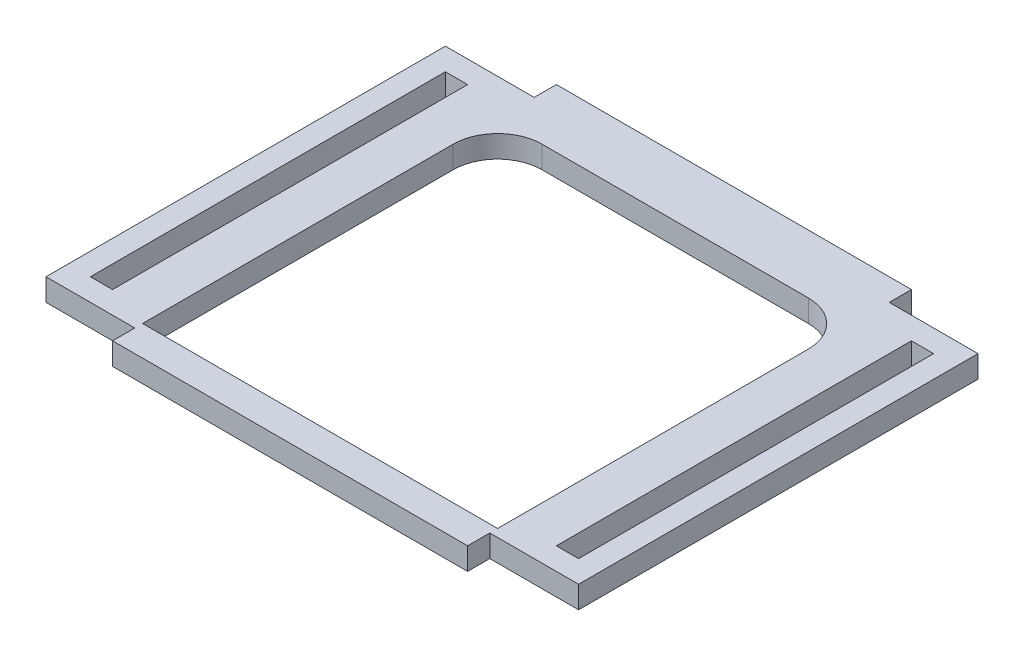
from build123d import *

# Parameters (mm, degrees)
SKETCH1_W               = 152.4
SKETCH1_H               = 127
BOSS_EXTRUDE1_DEPTH     = 6.35
SKETCH2_W               = 25.4
SKETCH2_H               = 6.35
SKETCH2_W_2             = 6.35
SKETCH2_H_2             = 101.6
CUT_EXTRUDE1_DEPTH      = 7.35
CUT_EXTRUDE1_DEPTH_BACK = 6.35
CUT_EXTRUDE2_DEPTH      = 127
CUT_EXTRUDE2_DEPTH_BACK = 127


with BuildPart() as part:
    # Sketch1 → Boss-Extrude1 (new body)
    with BuildSketch(Plane(origin=(0, 0, 0), x_dir=(1, 0, 0), z_dir=(0, 1, 0))):
        Rectangle(SKETCH1_W, SKETCH1_H)
    extrude(amount=BOSS_EXTRUDE1_DEPTH)

    # Sketch2 → Cut-Extrude1 (cut, two sides)
    with BuildSketch(Plane(origin=(0, 0, 0), x_dir=(1, 0, 0), z_dir=(0, 1, 0))) as cut_extrude1_sk:
        with Locations((-63.5, 60.325)):
            Rectangle(SKETCH2_W, SKETCH2_H)
        with Locations((-63.5, -60.325)):
            Rectangle(SKETCH2_W, SKETCH2_H)
        with Locations((63.5, -60.325)):
            Rectangle(SKETCH2_W, SKETCH2_H)
        with Locations((63.5, 60.325)):
            Rectangle(SKETCH2_W, SKETCH2_H)
        with Locations((66.675, 0)):
            Rectangle(SKETCH2_W_2, SKETCH2_H_2)
        with Locations((-66.675, 0)):
            Rectangle(SKETCH2_W_2, SKETCH2_H_2)
    extrude(amount=CUT_EXTRUDE1_DEPTH, mode=Mode.SUBTRACT)
    extrude(cut_extrude1_sk.sketch, amount=-CUT_EXTRUDE1_DEPTH_BACK, mode=Mode.SUBTRACT)

    # Sketch3 → Cut-Extrude2 (cut, two sides)
    with BuildSketch(Plane(origin=(0, 0, 0), x_dir=(1, 0, 0), z_dir=(0, 1, 0))) as cut_extrude2_sk:
        with BuildLine():
            Line((-50.8, -54.914183245), (50.8, -54.914183245))
            Line((50.8, -54.914183245), (50.8, 33.985816755))
            ThreePointArc((50.8, 33.985816755), (47.080256121, 42.966072876), (38.1, 46.685816755))
            Line((38.1, 46.685816755), (-38.1, 46.685816755))
            ThreePointArc((-38.1, 46.685816755), (-47.080256121, 42.966072876), (-50.8, 33.985816755))
            Line((-50.8, 33.985816755), (-50.8, -54.914183245))
        make_face()
    extrude(amount=CUT_EXTRUDE2_DEPTH, mode=Mode.SUBTRACT)
    extrude(cut_extrude2_sk.sketch, amount=-CUT_EXTRUDE2_DEPTH_BACK, mode=Mode.SUBTRACT)


solid = part.part
